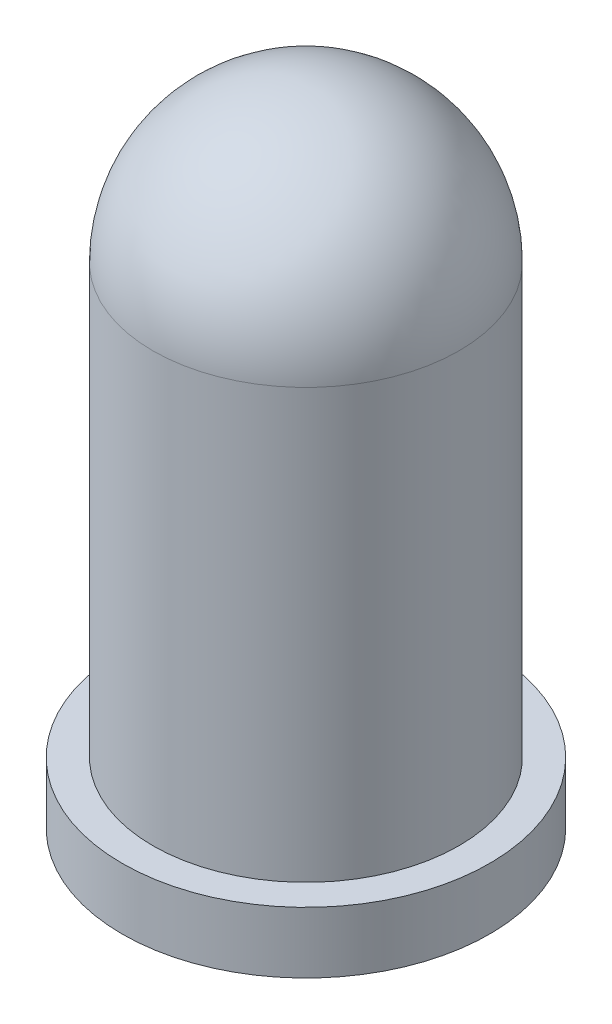
from build123d import *


with BuildPart() as part:
    # Sketch2 one side → Revolve4 (revolve)
    with BuildSketch(Plane.XY):
        with BuildLine():
            ThreePointArc((2.5, 8), (1.767766953, 9.767766953), (0, 10.5))
            Line((0, 10.5), (0, 0))
            Line((0, 0), (3, 0))
            Line((3, 0), (3, 1))
            Line((3, 1), (2.5, 1))
            Line((2.5, 1), (2.5, 8))
        make_face()
    revolve(axis=Axis((0, 12.90625, 0), (0, -1, 0)))


solid = part.part
